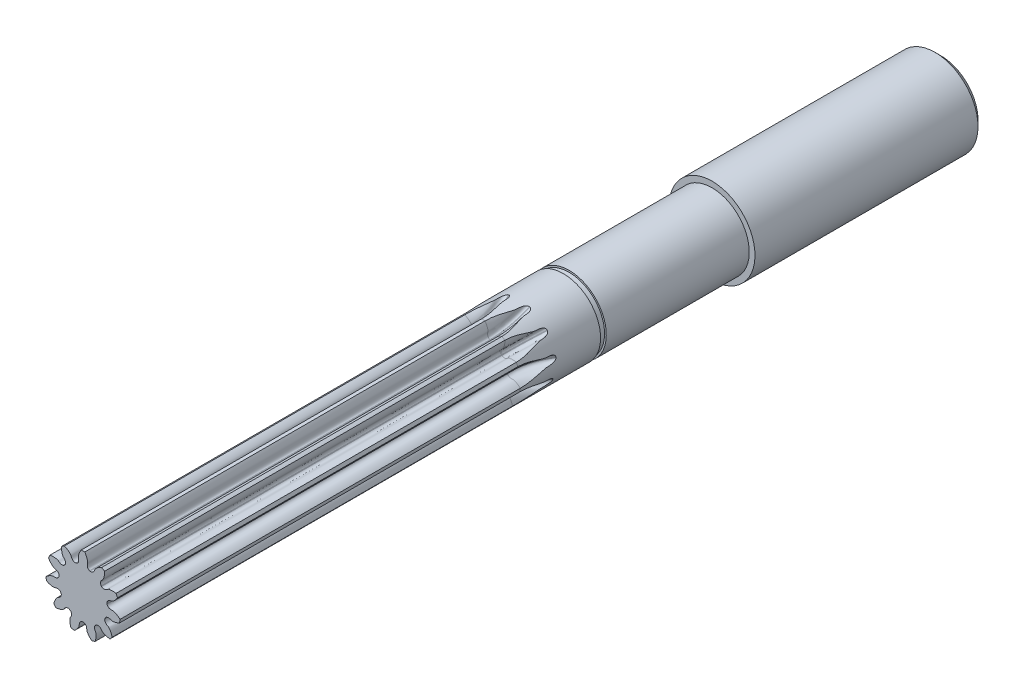
from build123d import *

# Parameters (mm, degrees)
EXTRUDE_1_DEPTH          = 70
PATTERN_CIRCULAR_1_COUNT = 11


with BuildPart() as part:
    # Эскиз1 → Бобышка-Вытянуть1 (new body)
    with BuildSketch(Plane.XY):
        with BuildLine():
            ThreePointArc((0.303, 6.493), (0, 6.500066), (-0.303, 6.493))
            add(Edge.make_bspline(
                [(-0.303, 6.493), (-0.346584218, 6.42959541), (-0.414908989, 6.322872217), (-0.503832534, 6.171085791), (-0.571642486, 6.040604913), (-0.631254096, 5.909462755), (-0.68518257, 5.779105167), (-0.72964324, 5.648408312), (-0.767399302, 5.518328721), (-0.797951002, 5.37284466), (-0.827792109, 5.196066136), (-0.768218484, 4.972302757), (-0.736721493, 4.755594452), (-0.753966504, 4.568401559), (-0.785235089, 4.447093131), (-0.829023332, 4.351746005), (-0.87759341, 4.275547448), (-0.932758863, 4.214584459), (-1.017734715, 4.14379099), (-1.09368593, 4.106410336), (-1.15, 4.092)],
                knots=[0, 0, 0, 0, 0.085617132, 0.140969585, 0.1957209, 0.24916994, 0.301247193, 0.352628837, 0.402767547, 0.451734397, 0.518547692, 0.59904648, 0.705842174, 0.760987907, 0.80705749, 0.844573024, 0.877292442, 0.9072362, 0.935685939, 1, 1, 1, 1], degree=3))
            ThreePointArc((-1.15, 4.092), (-1.197511317, 4.07834901), (-1.244860662, 4.064146396))
            add(Edge.make_bspline(
                [(-3.255481007, 5.626073356), (-3.184536521, 5.596297428), (-3.069359152, 5.543455325), (-2.912489968, 5.463840156), (-2.784901317, 5.390733484), (-2.663852036, 5.31263815), (-2.548007884, 5.232130303), (-2.439945133, 5.146218365), (-2.337856377, 5.057200918), (-2.23350003, 4.951329433), (-2.112822407, 4.818747197), (-2.041963313, 4.59829753), (-1.951298913, 4.398962343), (-1.835587368, 4.250809018), (-1.743698272, 4.165662948), (-1.655312711, 4.109125552), (-1.573256911, 4.071282214), (-1.493889699, 4.04982158), (-1.384129623, 4.036207738), (-1.300025889, 4.045823457), (-1.244860662, 4.064146396)],
                knots=[0, 0, 0, 0, 0.085617132, 0.140969585, 0.1957209, 0.24916994, 0.301247193, 0.352628837, 0.402767547, 0.451734397, 0.518547692, 0.59904648, 0.705842174, 0.760987907, 0.80705749, 0.844573024, 0.877292442, 0.9072362, 0.935685939, 1, 1, 1, 1], degree=3))
            ThreePointArc((-3.255481007, 5.626073356), (-3.514200996, 5.468203486), (-3.765280648, 5.298445021))
            add(Edge.make_bspline(
                [(-3.765280648, 5.298445021), (-3.767666916, 5.221542278), (-3.767446457, 5.094821856), (-3.760191766, 4.91905529), (-3.746693839, 4.772626962), (-3.725941513, 4.630074689), (-3.700832399, 4.491254973), (-3.66757504, 4.357268529), (-3.629011125, 4.227426146), (-3.576058228, 4.08851967), (-3.50558848, 3.923670791), (-3.334496341, 3.767636991), (-3.190838031, 3.602358923), (-3.104141339, 3.435558884), (-3.064861858, 3.316602666), (-3.050150324, 3.212717849), (-3.049814024, 3.122356577), (-3.063263076, 3.041246552), (-3.096475473, 2.935749881), (-3.140160193, 2.863240947), (-3.179743788, 2.820672516)],
                knots=[0, 0, 0, 0, 0.085617132, 0.140969585, 0.1957209, 0.24916994, 0.301247193, 0.352628837, 0.402767547, 0.451734397, 0.518547692, 0.59904648, 0.705842174, 0.760987907, 0.80705749, 0.844573024, 0.877292442, 0.9072362, 0.935685939, 1, 1, 1, 1], degree=3))
            ThreePointArc((-3.179743788, 2.820672516), (-3.212332568, 2.783502015), (-3.24448686, 2.745955028))
            add(Edge.make_bspline(
                [(-5.780369797, 2.972908174), (-5.704589415, 2.986214554), (-5.579127449, 3.004030536), (-5.404117483, 3.021863877), (-5.257258629, 3.029342263), (-5.113203968, 3.029088471), (-4.972223838, 3.023991037), (-4.834868167, 3.010140449), (-4.700859174, 2.990447556), (-4.555830583, 2.957802096), (-4.382630738, 2.91151007), (-4.203836187, 2.764365327), (-4.019795702, 2.645690773), (-3.842355221, 2.583614649), (-3.719019753, 2.561664212), (-3.614098664, 2.561886771), (-3.524609278, 2.574413643), (-3.446238836, 2.599268963), (-3.346542586, 2.647157048), (-3.280988673, 2.700716217), (-3.24448686, 2.745955028)],
                knots=[0, 0, 0, 0, 0.085617132, 0.140969585, 0.1957209, 0.24916994, 0.301247193, 0.352628837, 0.402767547, 0.451734397, 0.518547692, 0.59904648, 0.705842174, 0.760987907, 0.80705749, 0.844573024, 0.877292442, 0.9072362, 0.935685939, 1, 1, 1, 1], degree=3))
            ThreePointArc((-5.780369797, 2.972908174), (-5.912668005, 2.700225002), (-6.032111295, 2.421671185))
            add(Edge.make_bspline(
                [(-6.032111295, 2.421671185), (-5.992541989, 2.355686367), (-5.923846295, 2.249201553), (-5.82271668, 2.105259491), (-5.732196371, 1.989373673), (-5.637668826, 1.880670624), (-5.541494091, 1.777463059), (-5.441077679, 1.682726776), (-5.338437556, 1.594345639), (-5.218792234, 1.506118572), (-5.070385277, 1.405537693), (-4.84209517, 1.366773102), (-4.631886039, 1.305399889), (-4.468773231, 1.211950537), (-4.371416643, 1.13311429), (-4.30287614, 1.053674476), (-4.253740234, 0.977839554), (-4.221202906, 0.902334353), (-4.192107146, 0.795628928), (-4.189655782, 0.711012789), (-4.19994139, 0.653801439)],
                knots=[0, 0, 0, 0, 0.085617132, 0.140969585, 0.1957209, 0.24916994, 0.301247193, 0.352628837, 0.402767547, 0.451734397, 0.518547692, 0.59904648, 0.705842174, 0.760987907, 0.80705749, 0.844573024, 0.877292442, 0.9072362, 0.935685939, 1, 1, 1, 1], degree=3))
            ThreePointArc((-4.19994139, 0.653801439), (-4.207260927, 0.604912798), (-4.214011404, 0.55594234))
            add(Edge.make_bspline(
                [(-6.470032018, -0.624134348), (-6.413475476, -0.571970341), (-6.317562201, -0.489152723), (-6.179975881, -0.379532831), (-6.060473472, -0.293843722), (-5.939149769, -0.216175396), (-5.817793856, -0.144244018), (-5.694754719, -0.081635791), (-5.571372399, -0.025751776), (-5.431717116, 0.025193492), (-5.260984775, 0.079889067), (-5.031020774, 0.052766665), (-4.812035757, 0.052431075), (-4.62920244, 0.096140883), (-4.513578739, 0.144355189), (-4.425433827, 0.201267041), (-4.356923104, 0.260186931), (-4.304431493, 0.323466817), (-4.246451924, 0.417652699), (-4.220260736, 0.498150661), (-4.214011404, 0.55594234)],
                knots=[0, 0, 0, 0, 0.085617132, 0.140969585, 0.1957209, 0.24916994, 0.301247193, 0.352628837, 0.402767547, 0.451734397, 0.518547692, 0.59904648, 0.705842174, 0.760987907, 0.80705749, 0.844573024, 0.877292442, 0.9072362, 0.935685939, 1, 1, 1, 1], degree=3))
            ThreePointArc((-6.470032018, -0.624134348), (-6.4339047, -0.925055842), (-6.383789226, -1.223966142))
            add(Edge.make_bspline(
                [(-6.383789226, -1.223966142), (-6.314827322, -1.258083321), (-6.199466789, -1.310524351), (-6.03657019, -1.376941321), (-5.897767057, -1.425491701), (-5.75947612, -1.465833076), (-5.622770562, -1.500660817), (-5.4870766, -1.526068839), (-5.352947784, -1.544928343), (-5.204596581, -1.55446453), (-5.025370575, -1.558843691), (-4.812362995, -1.468031591), (-4.602342957, -1.406014386), (-4.414601197, -1.396443541), (-4.29007753, -1.410129868), (-4.189469184, -1.439903098), (-4.107133975, -1.477134618), (-4.03894064, -1.523062628), (-3.956774421, -1.597098588), (-3.908965263, -1.666956907), (-3.886687276, -1.720646976)],
                knots=[0, 0, 0, 0, 0.085617132, 0.140969585, 0.1957209, 0.24916994, 0.301247193, 0.352628837, 0.402767547, 0.451734397, 0.518547692, 0.59904648, 0.705842174, 0.760987907, 0.80705749, 0.844573024, 0.877292442, 0.9072362, 0.935685939, 1, 1, 1, 1], degree=3))
            ThreePointArc((-3.886687276, -1.720646976), (-3.866413668, -1.765731958), (-3.845617102, -1.810578113))
            add(Edge.make_bspline(
                [(-5.105504789, -4.023018624), (-5.08612839, -3.948558694), (-5.050215592, -3.827033449), (-4.993735603, -3.660430547), (-4.939530809, -3.523736401), (-4.879457483, -3.392805102), (-4.816255431, -3.266682615), (-4.746596885, -3.147493244), (-4.673014252, -3.0337751), (-4.583071843, -2.915413868), (-4.469013319, -2.777096149), (-4.260891813, -2.67558504), (-4.07648846, -2.557475118), (-3.946310592, -2.421856933), (-3.875108367, -2.318785587), (-3.831725018, -2.223253553), (-3.805944628, -2.136647294), (-3.795997565, -2.055033759), (-3.798142779, -1.944453431), (-3.819629834, -1.862574211), (-3.845617102, -1.810578113)],
                knots=[0, 0, 0, 0, 0.085617132, 0.140969585, 0.1957209, 0.24916994, 0.301247193, 0.352628837, 0.402767547, 0.451734397, 0.518547692, 0.59904648, 0.705842174, 0.760987907, 0.80705749, 0.844573024, 0.877292442, 0.9072362, 0.935685939, 1, 1, 1, 1], degree=3))
            ThreePointArc((-5.105504789, -4.023018624), (-4.912422113, -4.256637991), (-4.708659184, -4.481002867))
            add(Edge.make_bspline(
                [(-4.708659184, -4.481002867), (-4.632199599, -4.472420444), (-4.506800382, -4.454168033), (-4.333855317, -4.421972993), (-4.190838374, -4.387773532), (-4.052690441, -4.346945132), (-3.918857109, -4.302335487), (-3.790967469, -4.250348381), (-3.667934912, -4.193698492), (-3.537978286, -4.121516127), (-3.384836222, -4.028303218), (-3.254739572, -3.836746626), (-3.111588505, -3.671029028), (-2.958824475, -3.561476663), (-2.846669114, -3.505667756), (-2.745935363, -3.476321613), (-2.656541699, -3.463128986), (-2.574343258, -3.464897986), (-2.465193774, -3.482758587), (-2.387205893, -3.515679562), (-2.339437414, -3.548802134)],
                knots=[0, 0, 0, 0, 0.085617132, 0.140969585, 0.1957209, 0.24916994, 0.301247193, 0.352628837, 0.402767547, 0.451734397, 0.518547692, 0.59904648, 0.705842174, 0.760987907, 0.80705749, 0.844573024, 0.877292442, 0.9072362, 0.935685939, 1, 1, 1, 1], degree=3))
            ThreePointArc((-2.339437414, -3.548802134), (-2.298007388, -3.575769294), (-2.256266542, -3.602252808))
            add(Edge.make_bspline(
                [(-2.120015863, -6.144622913), (-2.143971476, -6.071507561), (-2.179461216, -5.949858095), (-2.222019554, -5.779167428), (-2.250322015, -5.634867671), (-2.270571922, -5.492243161), (-2.285589937, -5.351972564), (-2.291428078, -5.214043831), (-2.291007098, -5.078596266), (-2.279333643, -4.930397924), (-2.258161711, -4.752372961), (-2.137959807, -4.554457401), (-2.04668488, -4.355401032), (-2.010493015, -4.170932286), (-2.006318469, -4.045728322), (-2.02147059, -3.941906852), (-2.046605625, -3.855111099), (-2.082361231, -3.781075636), (-2.143950139, -3.689209335), (-2.206293448, -3.631944931), (-2.256266542, -3.602252808)],
                knots=[0, 0, 0, 0, 0.085617132, 0.140969585, 0.1957209, 0.24916994, 0.301247193, 0.352628837, 0.402767547, 0.451734397, 0.518547692, 0.59904648, 0.705842174, 0.760987907, 0.80705749, 0.844573024, 0.877292442, 0.9072362, 0.935685939, 1, 1, 1, 1], degree=3))
            ThreePointArc((-2.120015863, -6.144622913), (-1.831280214, -6.236767655), (-1.538563121, -6.315352842))
            add(Edge.make_bspline(
                [(-1.538563121, -6.315352842), (-1.478881232, -6.266795677), (-1.383256697, -6.183644836), (-1.255172002, -6.063059484), (-1.153348118, -5.956968269), (-1.059204181, -5.847932822), (-0.970734213, -5.738049039), (-0.891252954, -5.625172343), (-0.818378622, -5.510999001), (-0.748076884, -5.380015475), (-0.669640285, -5.218804936), (-0.663759331, -4.987321716), (-0.632926688, -4.770517892), (-0.563641889, -4.595766108), (-0.499463367, -4.488180901), (-0.430586467, -4.409032577), (-0.362516204, -4.34960437), (-0.292410081, -4.306652715), (-0.190931522, -4.262667342), (-0.107525519, -4.248198797), (-0.049432703, -4.250237688)],
                knots=[0, 0, 0, 0, 0.085617132, 0.140969585, 0.1957209, 0.24916994, 0.301247193, 0.352628837, 0.402767547, 0.451734397, 0.518547692, 0.59904648, 0.705842174, 0.760987907, 0.80705749, 0.844573024, 0.877292442, 0.9072362, 0.935685939, 1, 1, 1, 1], degree=3))
            ThreePointArc((-0.049432703, -4.250237688), (0, -4.250525144), (0.049432703, -4.250237688))
            add(Edge.make_bspline(
                [(1.538563121, -6.315352842), (1.478881232, -6.266795677), (1.383256697, -6.183644836), (1.255172002, -6.063059484), (1.153348118, -5.956968269), (1.059204181, -5.847932822), (0.970734213, -5.738049039), (0.891252954, -5.625172343), (0.818378622, -5.510999001), (0.748076884, -5.380015475), (0.669640285, -5.218804936), (0.663759331, -4.987321716), (0.632926688, -4.770517892), (0.563641889, -4.595766108), (0.499463367, -4.488180901), (0.430586467, -4.409032577), (0.362516204, -4.34960437), (0.292410081, -4.306652715), (0.190931522, -4.262667342), (0.107525519, -4.248198797), (0.049432703, -4.250237688)],
                knots=[0, 0, 0, 0, 0.085617132, 0.140969585, 0.1957209, 0.24916994, 0.301247193, 0.352628837, 0.402767547, 0.451734397, 0.518547692, 0.59904648, 0.705842174, 0.760987907, 0.80705749, 0.844573024, 0.877292442, 0.9072362, 0.935685939, 1, 1, 1, 1], degree=3))
            ThreePointArc((1.538563121, -6.315352842), (1.831280214, -6.236767655), (2.120015863, -6.144622913))
            add(Edge.make_bspline(
                [(2.120015863, -6.144622913), (2.143971476, -6.071507561), (2.179461216, -5.949858095), (2.222019554, -5.779167428), (2.250322015, -5.634867671), (2.270571922, -5.492243161), (2.285589937, -5.351972564), (2.291428078, -5.214043831), (2.291007098, -5.078596266), (2.279333643, -4.930397924), (2.258161711, -4.752372961), (2.137959807, -4.554457401), (2.04668488, -4.355401032), (2.010493015, -4.170932286), (2.006318469, -4.045728322), (2.02147059, -3.941906852), (2.046605625, -3.855111099), (2.082361231, -3.781075636), (2.143950139, -3.689209335), (2.206293448, -3.631944931), (2.256266542, -3.602252808)],
                knots=[0, 0, 0, 0, 0.085617132, 0.140969585, 0.1957209, 0.24916994, 0.301247193, 0.352628837, 0.402767547, 0.451734397, 0.518547692, 0.59904648, 0.705842174, 0.760987907, 0.80705749, 0.844573024, 0.877292442, 0.9072362, 0.935685939, 1, 1, 1, 1], degree=3))
            ThreePointArc((2.256266542, -3.602252808), (2.298007388, -3.575769294), (2.339437414, -3.548802134))
            add(Edge.make_bspline(
                [(4.708659184, -4.481002867), (4.632199599, -4.472420444), (4.506800382, -4.454168033), (4.333855317, -4.421972993), (4.190838374, -4.387773532), (4.052690441, -4.346945132), (3.918857109, -4.302335487), (3.790967469, -4.250348381), (3.667934912, -4.193698492), (3.537978286, -4.121516127), (3.384836222, -4.028303218), (3.254739572, -3.836746626), (3.111588505, -3.671029028), (2.958824475, -3.561476663), (2.846669114, -3.505667756), (2.745935363, -3.476321613), (2.656541699, -3.463128986), (2.574343258, -3.464897986), (2.465193774, -3.482758587), (2.387205893, -3.515679562), (2.339437414, -3.548802134)],
                knots=[0, 0, 0, 0, 0.085617132, 0.140969585, 0.1957209, 0.24916994, 0.301247193, 0.352628837, 0.402767547, 0.451734397, 0.518547692, 0.59904648, 0.705842174, 0.760987907, 0.80705749, 0.844573024, 0.877292442, 0.9072362, 0.935685939, 1, 1, 1, 1], degree=3))
            ThreePointArc((4.708659184, -4.481002867), (4.912422113, -4.256637991), (5.105504789, -4.023018624))
            add(Edge.make_bspline(
                [(5.105504789, -4.023018624), (5.08612839, -3.948558694), (5.050215592, -3.827033449), (4.993735603, -3.660430547), (4.939530809, -3.523736401), (4.879457483, -3.392805102), (4.816255431, -3.266682615), (4.746596885, -3.147493244), (4.673014252, -3.0337751), (4.583071843, -2.915413868), (4.469013319, -2.777096149), (4.260891813, -2.67558504), (4.07648846, -2.557475118), (3.946310592, -2.421856933), (3.875108367, -2.318785587), (3.831725018, -2.223253553), (3.805944628, -2.136647294), (3.795997565, -2.055033759), (3.798142779, -1.944453431), (3.819629834, -1.862574211), (3.845617102, -1.810578113)],
                knots=[0, 0, 0, 0, 0.085617132, 0.140969585, 0.1957209, 0.24916994, 0.301247193, 0.352628837, 0.402767547, 0.451734397, 0.518547692, 0.59904648, 0.705842174, 0.760987907, 0.80705749, 0.844573024, 0.877292442, 0.9072362, 0.935685939, 1, 1, 1, 1], degree=3))
            ThreePointArc((3.845617102, -1.810578113), (3.866413668, -1.765731958), (3.886687276, -1.720646976))
            add(Edge.make_bspline(
                [(6.383789226, -1.223966142), (6.314827322, -1.258083321), (6.199466789, -1.310524351), (6.03657019, -1.376941321), (5.897767057, -1.425491701), (5.75947612, -1.465833076), (5.622770562, -1.500660817), (5.4870766, -1.526068839), (5.352947784, -1.544928343), (5.204596581, -1.55446453), (5.025370575, -1.558843691), (4.812362995, -1.468031591), (4.602342957, -1.406014386), (4.414601197, -1.396443541), (4.29007753, -1.410129868), (4.189469184, -1.439903098), (4.107133975, -1.477134618), (4.03894064, -1.523062628), (3.956774421, -1.597098588), (3.908965263, -1.666956907), (3.886687276, -1.720646976)],
                knots=[0, 0, 0, 0, 0.085617132, 0.140969585, 0.1957209, 0.24916994, 0.301247193, 0.352628837, 0.402767547, 0.451734397, 0.518547692, 0.59904648, 0.705842174, 0.760987907, 0.80705749, 0.844573024, 0.877292442, 0.9072362, 0.935685939, 1, 1, 1, 1], degree=3))
            ThreePointArc((6.383789226, -1.223966142), (6.4339047, -0.925055842), (6.470032018, -0.624134348))
            add(Edge.make_bspline(
                [(6.470032018, -0.624134348), (6.413475476, -0.571970341), (6.317562201, -0.489152723), (6.179975881, -0.379532831), (6.060473472, -0.293843722), (5.939149769, -0.216175396), (5.817793856, -0.144244018), (5.694754719, -0.081635791), (5.571372399, -0.025751776), (5.431717116, 0.025193492), (5.260984775, 0.079889067), (5.031020774, 0.052766665), (4.812035757, 0.052431075), (4.62920244, 0.096140883), (4.513578739, 0.144355189), (4.425433827, 0.201267041), (4.356923104, 0.260186931), (4.304431493, 0.323466817), (4.246451924, 0.417652699), (4.220260736, 0.498150661), (4.214011404, 0.55594234)],
                knots=[0, 0, 0, 0, 0.085617132, 0.140969585, 0.1957209, 0.24916994, 0.301247193, 0.352628837, 0.402767547, 0.451734397, 0.518547692, 0.59904648, 0.705842174, 0.760987907, 0.80705749, 0.844573024, 0.877292442, 0.9072362, 0.935685939, 1, 1, 1, 1], degree=3))
            ThreePointArc((4.214011404, 0.55594234), (4.207260927, 0.604912798), (4.19994139, 0.653801439))
            add(Edge.make_bspline(
                [(6.032111295, 2.421671185), (5.992541989, 2.355686367), (5.923846295, 2.249201553), (5.82271668, 2.105259491), (5.732196371, 1.989373673), (5.637668826, 1.880670624), (5.541494091, 1.777463059), (5.441077679, 1.682726776), (5.338437556, 1.594345639), (5.218792234, 1.506118572), (5.070385277, 1.405537693), (4.84209517, 1.366773102), (4.631886039, 1.305399889), (4.468773231, 1.211950537), (4.371416643, 1.13311429), (4.30287614, 1.053674476), (4.253740234, 0.977839554), (4.221202906, 0.902334353), (4.192107146, 0.795628928), (4.189655782, 0.711012789), (4.19994139, 0.653801439)],
                knots=[0, 0, 0, 0, 0.085617132, 0.140969585, 0.1957209, 0.24916994, 0.301247193, 0.352628837, 0.402767547, 0.451734397, 0.518547692, 0.59904648, 0.705842174, 0.760987907, 0.80705749, 0.844573024, 0.877292442, 0.9072362, 0.935685939, 1, 1, 1, 1], degree=3))
            ThreePointArc((6.032111295, 2.421671185), (5.912668005, 2.700225002), (5.780369797, 2.972908174))
            add(Edge.make_bspline(
                [(5.780369797, 2.972908174), (5.704589415, 2.986214554), (5.579127449, 3.004030536), (5.404117483, 3.021863877), (5.257258629, 3.029342263), (5.113203968, 3.029088471), (4.972223838, 3.023991037), (4.834868167, 3.010140449), (4.700859174, 2.990447556), (4.555830583, 2.957802096), (4.382630738, 2.91151007), (4.203836187, 2.764365327), (4.019795702, 2.645690773), (3.842355221, 2.583614649), (3.719019753, 2.561664212), (3.614098664, 2.561886771), (3.524609278, 2.574413643), (3.446238836, 2.599268963), (3.346542586, 2.647157048), (3.280988673, 2.700716217), (3.24448686, 2.745955028)],
                knots=[0, 0, 0, 0, 0.085617132, 0.140969585, 0.1957209, 0.24916994, 0.301247193, 0.352628837, 0.402767547, 0.451734397, 0.518547692, 0.59904648, 0.705842174, 0.760987907, 0.80705749, 0.844573024, 0.877292442, 0.9072362, 0.935685939, 1, 1, 1, 1], degree=3))
            ThreePointArc((3.24448686, 2.745955028), (3.212332568, 2.783502015), (3.179743788, 2.820672516))
            add(Edge.make_bspline(
                [(3.765280648, 5.298445021), (3.767666916, 5.221542278), (3.767446457, 5.094821856), (3.760191766, 4.91905529), (3.746693839, 4.772626962), (3.725941513, 4.630074689), (3.700832399, 4.491254973), (3.66757504, 4.357268529), (3.629011125, 4.227426146), (3.576058228, 4.08851967), (3.50558848, 3.923670791), (3.334496341, 3.767636991), (3.190838031, 3.602358923), (3.104141339, 3.435558884), (3.064861858, 3.316602666), (3.050150324, 3.212717849), (3.049814024, 3.122356577), (3.063263076, 3.041246552), (3.096475473, 2.935749881), (3.140160193, 2.863240947), (3.179743788, 2.820672516)],
                knots=[0, 0, 0, 0, 0.085617132, 0.140969585, 0.1957209, 0.24916994, 0.301247193, 0.352628837, 0.402767547, 0.451734397, 0.518547692, 0.59904648, 0.705842174, 0.760987907, 0.80705749, 0.844573024, 0.877292442, 0.9072362, 0.935685939, 1, 1, 1, 1], degree=3))
            ThreePointArc((3.765280648, 5.298445021), (3.514200996, 5.468203486), (3.255481007, 5.626073356))
            add(Edge.make_bspline(
                [(3.255481007, 5.626073356), (3.184536521, 5.596297428), (3.069359152, 5.543455325), (2.912489968, 5.463840156), (2.784901317, 5.390733484), (2.663852036, 5.31263815), (2.548007884, 5.232130303), (2.439945133, 5.146218365), (2.337856377, 5.057200918), (2.23350003, 4.951329433), (2.112822407, 4.818747197), (2.041963313, 4.59829753), (1.951298913, 4.398962343), (1.835587368, 4.250809018), (1.743698272, 4.165662948), (1.655312711, 4.109125552), (1.573256911, 4.071282214), (1.493889699, 4.04982158), (1.384129623, 4.036207738), (1.300025889, 4.045823457), (1.244860662, 4.064146396)],
                knots=[0, 0, 0, 0, 0.085617132, 0.140969585, 0.1957209, 0.24916994, 0.301247193, 0.352628837, 0.402767547, 0.451734397, 0.518547692, 0.59904648, 0.705842174, 0.760987907, 0.80705749, 0.844573024, 0.877292442, 0.9072362, 0.935685939, 1, 1, 1, 1], degree=3))
            ThreePointArc((1.244860662, 4.064146396), (1.197511317, 4.07834901), (1.15, 4.092))
            add(Edge.make_bspline(
                [(0.303, 6.493), (0.346584218, 6.42959541), (0.414908989, 6.322872217), (0.503832534, 6.171085791), (0.571642486, 6.040604913), (0.631254096, 5.909462755), (0.68518257, 5.779105167), (0.72964324, 5.648408312), (0.767399302, 5.518328721), (0.797951002, 5.37284466), (0.827792109, 5.196066136), (0.768218484, 4.972302757), (0.736721493, 4.755594452), (0.753966504, 4.568401559), (0.785235089, 4.447093131), (0.829023332, 4.351746005), (0.87759341, 4.275547448), (0.932758863, 4.214584459), (1.017734715, 4.14379099), (1.09368593, 4.106410336), (1.15, 4.092)],
                knots=[0, 0, 0, 0, 0.085617132, 0.140969585, 0.1957209, 0.24916994, 0.301247193, 0.352628837, 0.402767547, 0.451734397, 0.518547692, 0.59904648, 0.705842174, 0.760987907, 0.80705749, 0.844573024, 0.877292442, 0.9072362, 0.935685939, 1, 1, 1, 1], degree=3))
        make_face()
    extrude(amount=EXTRUDE_1_DEPTH)

    # Эскиз3 → Повернуть1 (revolve)
    with BuildSketch(Plane(origin=(0, 0, 0), x_dir=(0, 0, -1), z_dir=(1, 0, 0))):
        Polygon((40, 6.5), (40, 7.5), (79, 7.5), (80, 6.5), (80, 0), (0, 0), (0, 6.5), (14, 6.5), (14, 6.2), (15, 6.2), (15, 6.5), align=None)
    revolve(axis=Axis((0, 0, -80), (0, 0, 1)))

    # Эскиз5 → Вырез-Повернуть1 (revolve, cut)
    with BuildSketch(Plane.XY):
        with BuildLine():
            ThreePointArc((4.668186259, 5.870096852), (2.112994176, 7.196197302), (-0.753514222, 7.46205175))
            ThreePointArc((-0.753514222, 7.46205175), (-0.260168872, 6.939463128), (0.303, 6.493))
            add(Edge.make_bspline(
                [(1.15, 4.092), (1.09368593, 4.106410336), (1.017734715, 4.14379099), (0.932758863, 4.214584459), (0.87759341, 4.275547448), (0.829023332, 4.351746005), (0.785235089, 4.447093131), (0.753966504, 4.568401559), (0.736721493, 4.755594452), (0.768218484, 4.972302757), (0.827792109, 5.196066136), (0.797951002, 5.37284466), (0.767399302, 5.518328721), (0.72964324, 5.648408312), (0.68518257, 5.779105167), (0.631254096, 5.909462755), (0.571642486, 6.040604913), (0.503832534, 6.171085791), (0.414908989, 6.322872217), (0.346584218, 6.42959541), (0.303, 6.493)],
                knots=[0, 0, 0, 0, 0.064314061, 0.0927638, 0.122707558, 0.155426976, 0.19294251, 0.239012093, 0.294157826, 0.40095352, 0.481452308, 0.548265603, 0.597232453, 0.647371163, 0.698752807, 0.75083006, 0.8042791, 0.859030415, 0.914382868, 1, 1, 1, 1], degree=3))
            ThreePointArc((1.15, 4.092), (1.197511317, 4.07834901), (1.244860662, 4.064146396))
            add(Edge.make_bspline(
                [(1.244860662, 4.064146396), (1.300025889, 4.045823457), (1.384129623, 4.036207738), (1.493889699, 4.04982158), (1.573256911, 4.071282214), (1.655312711, 4.109125552), (1.743698272, 4.165662948), (1.835587368, 4.250809018), (1.951298913, 4.398962343), (2.041963313, 4.59829753), (2.112822407, 4.818747197), (2.23350003, 4.951329433), (2.337856377, 5.057200918), (2.439945133, 5.146218365), (2.548007884, 5.232130303), (2.663852036, 5.31263815), (2.784901317, 5.390733484), (2.912489968, 5.463840156), (3.069359152, 5.543455325), (3.184536521, 5.596297428), (3.255481007, 5.626073356)],
                knots=[0, 0, 0, 0, 0.064314061, 0.0927638, 0.122707558, 0.155426976, 0.19294251, 0.239012093, 0.294157826, 0.40095352, 0.481452308, 0.548265603, 0.597232453, 0.647371163, 0.698752807, 0.75083006, 0.8042791, 0.859030415, 0.914382868, 1, 1, 1, 1], degree=3))
            ThreePointArc((3.255481007, 5.626073356), (3.970625001, 5.697189961), (4.668186259, 5.870096852))
        make_face()
    cut_revolve_1 = revolve(axis=Axis((2.486427316, 13.929070546, 0), (0.959492974, -0.281732557, 0)), mode=Mode.SUBTRACT)

    # Круговой массив1: Вырез-Повернуть1 ×11 about axis
    pattern_circular_1_axis = Axis((0, 0, -80), (0, 0, -1))
    for i in range(1, PATTERN_CIRCULAR_1_COUNT):
        add(cut_revolve_1.rotate(pattern_circular_1_axis, i * 360 / PATTERN_CIRCULAR_1_COUNT), mode=Mode.SUBTRACT)


solid = part.part
